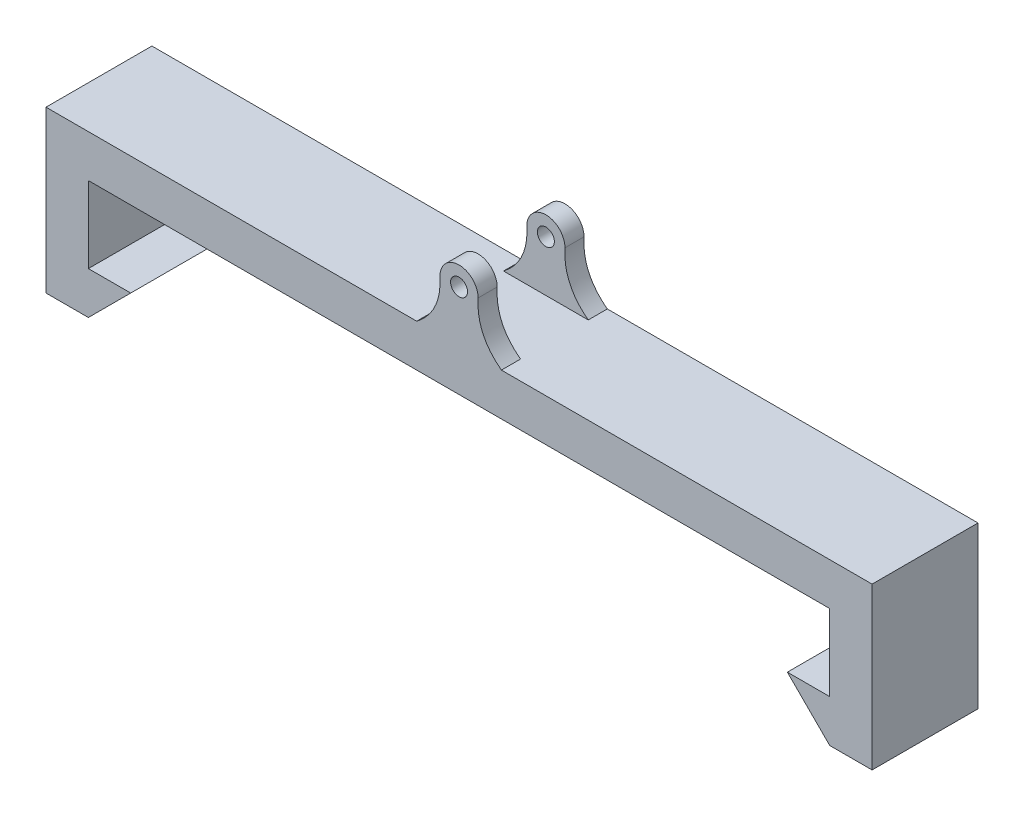
from build123d import *

# Parameters (mm, degrees)
BOSS_EXTRU_1_DEPTH = 25
ESQUISSE2_R        = 2
BOSS_EXTRU_2_DEPTH = 4.5
ESQUISSE4_R        = 2
BOSS_EXTRU_3_DEPTH = 4.5


with BuildPart() as part:
    # Esquisse1 → Boss.-Extru.1 (new body)
    with BuildSketch(Plane.XY):
        Polygon((0, 0), (195, 0), (195, -38), (185, -38), (175, -28), (185, -28), (185, -10), (10, -10), (10, -28), (20, -28), (10, -38), (0, -38), align=None)
    extrude(amount=BOSS_EXTRU_1_DEPTH)

    # Esquisse2 → Boss.-Extru.2 (add)
    with BuildSketch(Plane.XY.offset(25)):
        with BuildLine():
            Line((97.5, 0), (87.5, 0))
            add(Edge.make_bspline(
                [(93, 12), (93.473540625, 4.530107825), (87.5, 0)],
                knots=[0, 0, 0, 1, 1, 1], degree=2))
            ThreePointArc((93, 12), (97.5, 16.5), (102, 12))
            add(Edge.make_bspline(
                [(102, 12), (101.526459375, 4.530107825), (107.5, 0)],
                knots=[0, 0, 0, 1, 1, 1], degree=2))
            Line((107.5, 0), (97.5, 0))
        make_face()
        with Locations((97.5, 12)):
            Circle(ESQUISSE2_R, mode=Mode.SUBTRACT)
    extrude(amount=-BOSS_EXTRU_2_DEPTH)

    # Esquisse4 → Boss.-Extru.3 (add)
    with BuildSketch(Plane(origin=(0, 0, 0), x_dir=(-1, 0, 0), z_dir=(0, 0, -1))):
        with BuildLine():
            Line((-97.5, 0), (-107.5, 0))
            add(Edge.make_bspline(
                [(-102, 12), (-101.527789756, 4.527189734), (-107.5, 0)],
                knots=[0, 0, 0, 1, 1, 1], degree=2))
            ThreePointArc((-102, 12), (-97.5, 16.5), (-93, 12))
            add(Edge.make_bspline(
                [(-93, 12), (-93.472210244, 4.527189734), (-87.5, 0)],
                knots=[0, 0, 0, 1, 1, 1], degree=2))
            Line((-87.5, 0), (-97.5, 0))
        make_face()
        with Locations((-97.5, 12)):
            Circle(ESQUISSE4_R, mode=Mode.SUBTRACT)
    extrude(amount=-BOSS_EXTRU_3_DEPTH)


solid = part.part
